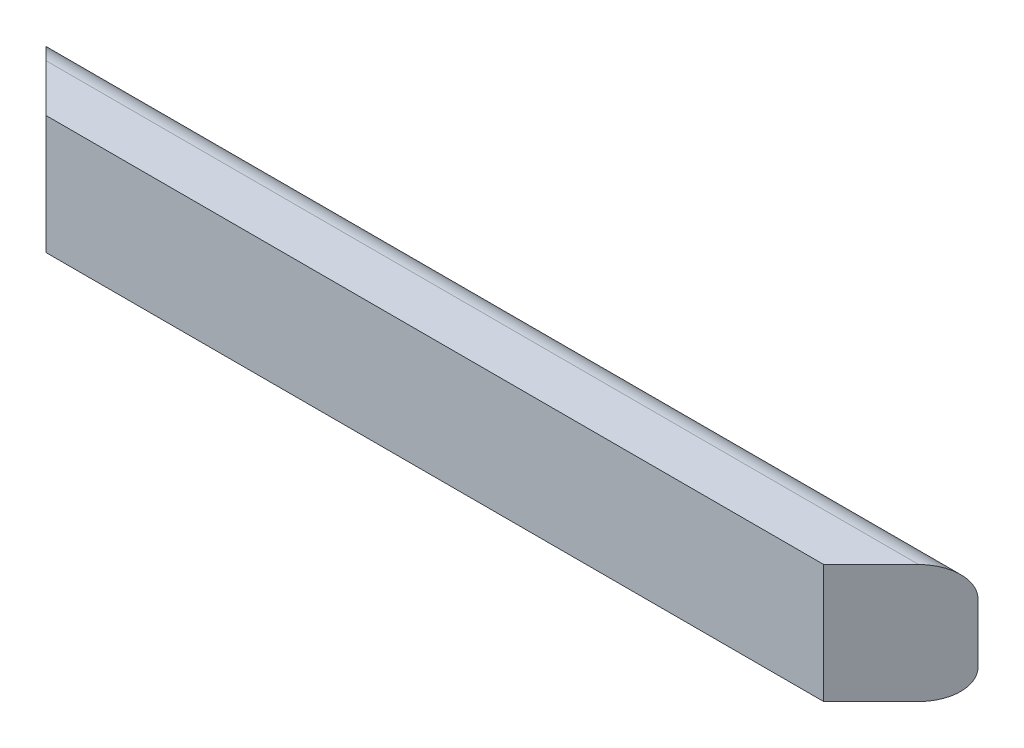
from build123d import *

# Parameters (mm, degrees)
BOSS_EXTRUDE1_DEPTH = 996.95
SKETCH2_W           = 344.402501539
SKETCH2_H           = 493.213131915
CUT_EXTRUDE1_DEPTH  = 59.371664787


with BuildPart() as part:
    # Sketch1 → Boss-Extrude1 (new body)
    with BuildSketch(Plane(origin=(0, 0, 0), x_dir=(0, 0, -1), z_dir=(1, 0, 0))):
        with BuildLine():
            Line((0, 0), (31.75, 0))
            ThreePointArc((31.75, 0), (54.200640303, 9.299359697), (63.5, 31.75))
            Line((63.5, 31.75), (63.5, 95.25))
            ThreePointArc((63.5, 95.25), (54.200640303, 117.700640303), (31.75, 127))
            Line((31.75, 127), (0, 127))
            Line((0, 127), (-19.05, 127))
            Line((-19.05, 127), (-19.05, 0))
            Line((-19.05, 0), (0, 0))
        make_face()
    extrude(amount=BOSS_EXTRUDE1_DEPTH)

    # Sketch2 → Cut-Extrude1 (cut, through all)
    with BuildSketch(Plane(origin=(466.725, 0, 466.725), x_dir=(0, 1, 0), z_dir=(0.707106781, 0, 0.707106781))):
        with Locations((32.995160032, -679.680893327)):
            Rectangle(SKETCH2_W, SKETCH2_H)
    cut_extrude1 = extrude(amount=CUT_EXTRUDE1_DEPTH, mode=Mode.SUBTRACT)

    # Mirror1: Cut-Extrude1 across plane
    add(cut_extrude1.mirror(Plane(origin=(498.475, 0, 0), x_dir=(0, 0, 1), z_dir=(1, 0, 0))), mode=Mode.SUBTRACT)


solid = part.part
